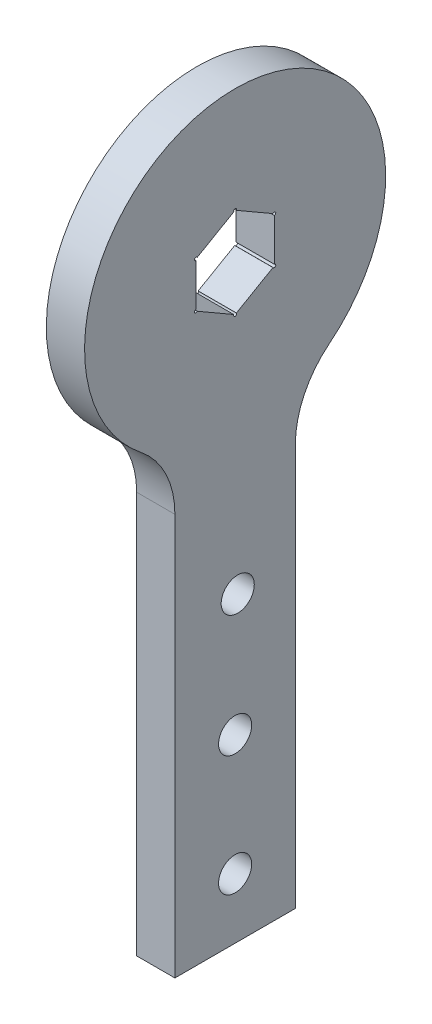
from build123d import *

# Parameters (mm, degrees)
BOSS_EXTRUDE1_DEPTH = 6.35
SKETCH2_R           = 2.75
CUT_EXTRUDE1_DEPTH  = 7.35
FILLET1_R           = 15
CUT_EXTRUDE2_REACH  = 8.35
CUT_EXTRUDE3_REACH  = 8.35
SKETCH4_R           = 0.25


with BuildPart() as part:
    # Sketch1 → Boss-Extrude1 (new body)
    with BuildSketch(Plane(origin=(0, 0, 0), x_dir=(0, 0, -1), z_dir=(1, 0, 0))):
        with BuildLine():
            Line((-10, -22.912878475), (-10, -97.912878475))
            Line((-10, -97.912878475), (10, -97.912878475))
            Line((10, -97.912878475), (10, -22.912878475))
            ThreePointArc((10, -22.912878475), (0, 25), (-10, -22.912878475))
        make_face()
    extrude(amount=BOSS_EXTRUDE1_DEPTH)

    # Sketch2 → Cut-Extrude1 (cut, through all)
    with BuildSketch(Plane(origin=(6.35, 0, 0), x_dir=(0, 0, -1), z_dir=(1, 0, 0))):
        with Locations((0, -87.912878475)):
            Circle(SKETCH2_R)
        with Locations((0, -67.912878475)):
            Circle(SKETCH2_R)
        with Locations((0.431184648, -47.912878475)):
            Circle(SKETCH2_R)
    extrude(amount=-CUT_EXTRUDE1_DEPTH, mode=Mode.SUBTRACT)

    # Fillet1
    fillet1_edges = [part.edges().sort_by_distance(p)[0] for p in [
        (3.175, -22.912878475, 10),
        (3.175, -22.912878475, -10),
    ]]
    fillet(fillet1_edges, radius=FILLET1_R)

    # Sketch3 → Cut-Extrude2 (cut, up to next)
    with BuildSketch(Plane(origin=(6.35, 0, 0), x_dir=(0, 0, -1), z_dir=(1, 0, 0)), mode=Mode.PRIVATE) as cut_extrude2_sk1:
        Polygon((0, -7.505553499), (6.5, -3.75277675), (6.5, 3.75277675), (0, 7.505553499), (-6.5, 3.75277675), (-6.5, -3.75277675), align=None)
    cut_extrude2_tool1 = extrude(cut_extrude2_sk1.sketch, amount=-CUT_EXTRUDE2_REACH, mode=Mode.PRIVATE) & part.part
    add(cut_extrude2_tool1.solids().sort_by_distance((6.35, 0, 0))[0], mode=Mode.SUBTRACT)

    # Sketch4 → Cut-Extrude3 (cut, up to next)
    with BuildSketch(Plane(origin=(6.35, 0, 0), x_dir=(0, 0, -1), z_dir=(1, 0, 0)), mode=Mode.PRIVATE) as cut_extrude3_sk1:
        with Locations((0, 7.505553499)):
            Circle(SKETCH4_R)
    cut_extrude3_tool1 = extrude(cut_extrude3_sk1.sketch, amount=-CUT_EXTRUDE3_REACH, mode=Mode.PRIVATE) & part.part
    add(cut_extrude3_tool1.solids().sort_by_distance((6.35, 7.505553, 0))[0], mode=Mode.SUBTRACT)
    # Sketch4 → Cut-Extrude3 (cut, up to next)
    with BuildSketch(Plane(origin=(6.35, 0, 0), x_dir=(0, 0, -1), z_dir=(1, 0, 0)), mode=Mode.PRIVATE) as cut_extrude3_sk2:
        with Locations((6.5, 3.75277675)):
            Circle(SKETCH4_R)
    cut_extrude3_tool2 = extrude(cut_extrude3_sk2.sketch, amount=-CUT_EXTRUDE3_REACH, mode=Mode.PRIVATE) & part.part
    add(cut_extrude3_tool2.solids().sort_by_distance((6.35, 3.752777, -6.5))[0], mode=Mode.SUBTRACT)
    # Sketch4 → Cut-Extrude3 (cut, up to next)
    with BuildSketch(Plane(origin=(6.35, 0, 0), x_dir=(0, 0, -1), z_dir=(1, 0, 0)), mode=Mode.PRIVATE) as cut_extrude3_sk3:
        with Locations((6.5, -3.75277675)):
            Circle(SKETCH4_R)
    cut_extrude3_tool3 = extrude(cut_extrude3_sk3.sketch, amount=-CUT_EXTRUDE3_REACH, mode=Mode.PRIVATE) & part.part
    add(cut_extrude3_tool3.solids().sort_by_distance((6.35, -3.752777, -6.5))[0], mode=Mode.SUBTRACT)
    # Sketch4 → Cut-Extrude3 (cut, up to next)
    with BuildSketch(Plane(origin=(6.35, 0, 0), x_dir=(0, 0, -1), z_dir=(1, 0, 0)), mode=Mode.PRIVATE) as cut_extrude3_sk4:
        with Locations((0, -7.505553499)):
            Circle(SKETCH4_R)
    cut_extrude3_tool4 = extrude(cut_extrude3_sk4.sketch, amount=-CUT_EXTRUDE3_REACH, mode=Mode.PRIVATE) & part.part
    add(cut_extrude3_tool4.solids().sort_by_distance((6.35, -7.505553, 0))[0], mode=Mode.SUBTRACT)
    # Sketch4 → Cut-Extrude3 (cut, up to next)
    with BuildSketch(Plane(origin=(6.35, 0, 0), x_dir=(0, 0, -1), z_dir=(1, 0, 0)), mode=Mode.PRIVATE) as cut_extrude3_sk5:
        with Locations((-6.5, -3.75277675)):
            Circle(SKETCH4_R)
    cut_extrude3_tool5 = extrude(cut_extrude3_sk5.sketch, amount=-CUT_EXTRUDE3_REACH, mode=Mode.PRIVATE) & part.part
    add(cut_extrude3_tool5.solids().sort_by_distance((6.35, -3.752777, 6.5))[0], mode=Mode.SUBTRACT)
    # Sketch4 → Cut-Extrude3 (cut, up to next)
    with BuildSketch(Plane(origin=(6.35, 0, 0), x_dir=(0, 0, -1), z_dir=(1, 0, 0)), mode=Mode.PRIVATE) as cut_extrude3_sk6:
        with Locations((-6.5, 3.75277675)):
            Circle(SKETCH4_R)
    cut_extrude3_tool6 = extrude(cut_extrude3_sk6.sketch, amount=-CUT_EXTRUDE3_REACH, mode=Mode.PRIVATE) & part.part
    add(cut_extrude3_tool6.solids().sort_by_distance((6.35, 3.752777, 6.5))[0], mode=Mode.SUBTRACT)


solid = part.part
